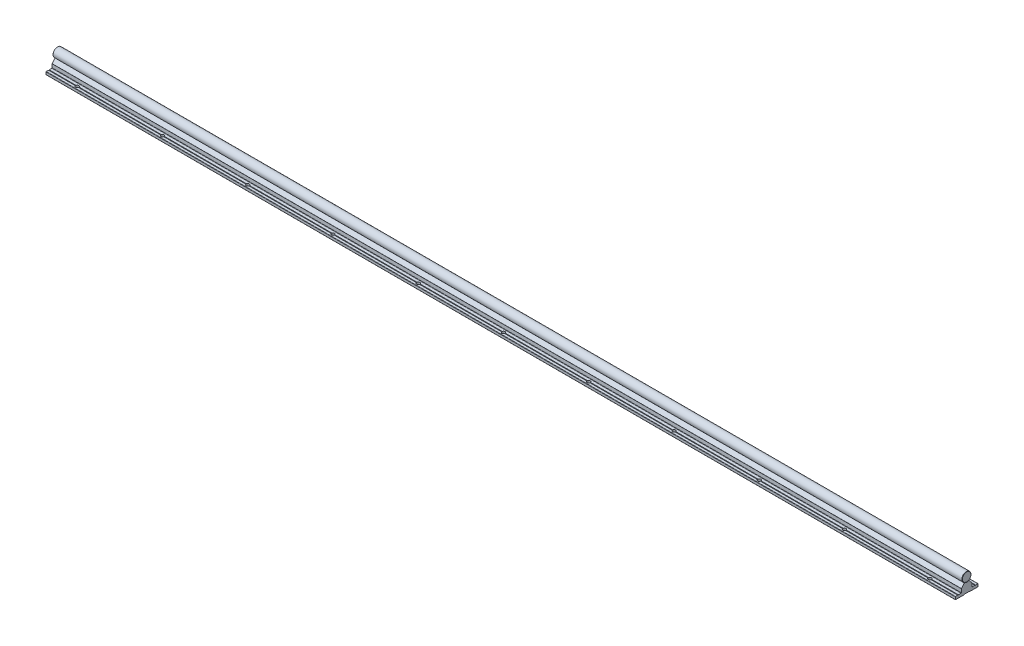
from build123d import *

# Parameters (mm, degrees)
EXTRUDE_6718_DEPTH       = 1500
SKETCH_1_3_R             = 8
EXTRUDE_6847_DEPTH       = 1500
FILLET_4_R               = 0.2
SKETCH_2_R               = 2.75
CUT_EXTRUDE_1_DEPTH      = 6
PATTERN_LINEAR_1_COUNT   = 20
PATTERN_LINEAR_1_PITCH   = 150
PATTERN_LINEAR_2_COUNT   = 20
PATTERN_LINEAR_2_PITCH   = 150
FILLET_1_R               = 0.3
CUT_EXTRUDE_2_DEPTH      = 3
FILLET_2_R               = 0.3
PATTERN_LINEAR_3_COUNT   = 20
PATTERN_LINEAR_3_PITCH   = 150
CHAMFER_1_SIZE           = 0.5
FILLET_3_R               = 0.5
FILLET_5_R               = 0.2
FILLET_6_R               = 0.1
FILLET_7_R               = 0.1
SKETCH_7_W               = 3500
SKETCH_7_H               = 1500
SKETCH_7_W_2             = 1600
SKETCH_7_H_2             = 1000
CUT_EXTRUDE_3_DEPTH      = 9.0000001
CUT_EXTRUDE_3_DEPTH_BACK = 26.0000001
CHAMFER_2_SIZE           = 0.5


with BuildPart() as part:
    # Sketch 1 → Extrude 6718 (new body, symmetric)
    with BuildSketch(Plane(origin=(0, 0, 0), x_dir=(0, 0, -1), z_dir=(1, 0, 0))):
        Polygon((-20, -25), (-4.75, -25), (-4.75, -24.4), (4.75, -24.4), (4.75, -25), (20, -25), (20, -20), (15.5, -20), (15, -20.5), (14.5, -20), (9.25, -20), (9.25, -13.3), (9.110116754, -13.3), (4, -7.21), (3.8, -7.21), (2.309327639, -7.659439004), (0, -8.355703281), (-2.309327657, -7.659438999), (-3.8, -7.21), (-4, -7.21), (-9.110116754, -13.3), (-9.25, -13.3), (-9.25, -20), (-14.5, -20), (-15, -20.5), (-15.5, -20), (-20, -20), align=None)
    extrude(amount=EXTRUDE_6718_DEPTH, both=True)

    # Fillet 4
    fillet_4_edges = [part.edges().sort_by_distance(p)[0] for p in [
        (0, -20, -15.5),
        (0, -24.4, -4.75),
        (0, -24.4, 4.75),
        (0, -20, 15.5),
        (0, -20, 14.5),
        (0, -8.355703281, 0),
        (0, -20, -14.5),
    ]]
    fillet(fillet_4_edges, radius=FILLET_4_R)

    # Sketch 2 → Cut-Extrude 1 (cut, through all)
    with BuildSketch(Plane(origin=(0, -20, 0), x_dir=(1, 0, 0), z_dir=(0, 1, 0))):
        with Locations((-1425, -15)):
            Circle(SKETCH_2_R)
        with Locations((-1425, 15)):
            Circle(SKETCH_2_R)
        with Locations((-1275, -15)):
            Circle(SKETCH_2_R)
        with Locations((-1275, 15)):
            Circle(SKETCH_2_R)
        with Locations((-1125, -15)):
            Circle(SKETCH_2_R)
        with Locations((-1125, 15)):
            Circle(SKETCH_2_R)
        with Locations((-975, -15)):
            Circle(SKETCH_2_R)
        with Locations((-975, 15)):
            Circle(SKETCH_2_R)
        with Locations((-825, -15)):
            Circle(SKETCH_2_R)
        with Locations((-825, 15)):
            Circle(SKETCH_2_R)
        with Locations((-675, -15)):
            Circle(SKETCH_2_R)
        with Locations((-675, 15)):
            Circle(SKETCH_2_R)
        with Locations((-525, -15)):
            Circle(SKETCH_2_R)
        with Locations((-525, 15)):
            Circle(SKETCH_2_R)
        with Locations((-375, -15)):
            Circle(SKETCH_2_R)
        with Locations((-375, 15)):
            Circle(SKETCH_2_R)
        with Locations((-225, -15)):
            Circle(SKETCH_2_R)
        with Locations((-225, 15)):
            Circle(SKETCH_2_R)
        with Locations((-75, -15)):
            Circle(SKETCH_2_R)
        with Locations((-75, 15)):
            Circle(SKETCH_2_R)
        with Locations((75, -15)):
            Circle(SKETCH_2_R)
        with Locations((75, 15)):
            Circle(SKETCH_2_R)
        with Locations((225, -15)):
            Circle(SKETCH_2_R)
        with Locations((225, 15)):
            Circle(SKETCH_2_R)
        with Locations((375, -15)):
            Circle(SKETCH_2_R)
        with Locations((375, 15)):
            Circle(SKETCH_2_R)
        with Locations((525, -15)):
            Circle(SKETCH_2_R)
        with Locations((525, 15)):
            Circle(SKETCH_2_R)
        with Locations((675, -15)):
            Circle(SKETCH_2_R)
        with Locations((675, 15)):
            Circle(SKETCH_2_R)
        with Locations((825, -15)):
            Circle(SKETCH_2_R)
        with Locations((825, 15)):
            Circle(SKETCH_2_R)
        with Locations((975, -15)):
            Circle(SKETCH_2_R)
        with Locations((975, 15)):
            Circle(SKETCH_2_R)
        with Locations((1125, -15)):
            Circle(SKETCH_2_R)
        with Locations((1125, 15)):
            Circle(SKETCH_2_R)
        with Locations((1275, -15)):
            Circle(SKETCH_2_R)
        with Locations((1275, 15)):
            Circle(SKETCH_2_R)
        with Locations((1425, -15)):
            Circle(SKETCH_2_R)
        with Locations((1425, 15)):
            Circle(SKETCH_2_R)
    extrude(amount=-CUT_EXTRUDE_1_DEPTH, mode=Mode.SUBTRACT)

    # Sketch 3 → Cut-Revolve 1 (revolve, cut)
    with BuildSketch(Plane.XY):
        Polygon((-1425, 0), (-1427.2, -1.270170592), (-1427.2, -7.5), (-1427.75, -7.5), (-1427.75, -19), (-1429.75, -19), (-1429.75, -24.4), (-1425, -24.4), align=None)
    cut_revolve_1 = revolve(axis=Axis((-1425, 56.434869358, 0), (0, -1, 0)), mode=Mode.SUBTRACT)

    # Pattern Linear 1: Cut-Revolve 1 ×20
    with Locations(*[(i * PATTERN_LINEAR_1_PITCH, 0, 0) for i in range(1, PATTERN_LINEAR_1_COUNT)]):
        add(cut_revolve_1, mode=Mode.SUBTRACT)

    # Fillet 3
    fillet_3_edges = [part.edges().sort_by_distance(p)[0] for p in [
        (0, -20, -9.25),
        (0, -20, -20),
        (0, -25, -20),
        (0, -25, -4.75),
        (0, -25, 4.75),
        (0, -20, 9.25),
        (0, -25, 20),
        (0, -20, 20),
    ]]
    fillet(fillet_3_edges, radius=FILLET_3_R)

    # Fillet 5
    fillet_5_edges = [part.edges().sort_by_distance(p)[0] for p in [
        (0, -7.21, 4),
        (0, -7.21, 3.8),
        (0, -7.21, -3.8),
        (0, -7.21, -4),
    ]]
    fillet(fillet_5_edges, radius=FILLET_5_R)

    # Fillet 6
    fillet_6_edges = [part.edges().sort_by_distance(p)[0] for p in [
        (0, -13.3, 9.25),
        (0, -13.3, -9.25),
    ]]
    fillet(fillet_6_edges, radius=FILLET_6_R)

    # Fillet 7
    fillet_7_edges = [part.edges().sort_by_distance(p)[0] for p in [
        (0, -13.3, 9.110116754),
        (0, -13.3, -9.110116754),
    ]]
    fillet(fillet_7_edges, radius=FILLET_7_R)


with BuildPart() as body_2:
    # Sketch 1_3 → Extrude 6847 (new body, symmetric)
    with BuildSketch(Plane(origin=(0, 0, 0), x_dir=(0, 0, -1), z_dir=(1, 0, 0))):
        Circle(SKETCH_1_3_R)
    extrude(amount=EXTRUDE_6847_DEPTH, both=True)

    # Sketch 4 → Cut-Revolve 2 (revolve, cut)
    with BuildSketch(Plane.XY):
        Polygon((-1425, -10), (-1427.2, -10), (-1427.2, -1.270170592), (-1425, 0), align=None)
    cut_revolve_2 = revolve(axis=Axis((-1425, 39.840222878, 0), (0, -1, 0)), mode=Mode.SUBTRACT)

    # Pattern Linear 2: Cut-Revolve 2 ×20
    with Locations(*[(i * PATTERN_LINEAR_2_PITCH, 0, 0) for i in range(1, PATTERN_LINEAR_2_COUNT)]):
        add(cut_revolve_2, mode=Mode.SUBTRACT)

    # Chamfer 1
    chamfer_1_edges = [body_2.edges().sort_by_distance(p)[0] for p in [
        (-1500, 0, 8),
        (1500, 0, 8),
    ]]
    chamfer(chamfer_1_edges, length=CHAMFER_1_SIZE)


with BuildPart() as body_3:
    # Sketch 5 → Revolve 1 (revolve)
    with BuildSketch(Plane.XY):
        Polygon((-1425, -24), (-1429.5, -24), (-1429.5, -19), (-1427.5, -19), (-1427.5, -2.461880215), (-1426.7, -2), (-1425, -2), align=None)
    revolve(axis=Axis((-1425, 35.529626596, 0), (0, -1, 0)))

    # Fillet 1
    fillet_1_edges = [body_3.edges().sort_by_distance(p)[0] for p in [
        (-1420.5, -19, 0),
    ]]
    fillet(fillet_1_edges, radius=FILLET_1_R)

    # Sketch 6 → Cut-Extrude 2 (cut)
    with BuildSketch(Plane.XZ.offset(24)):
        Polygon((-1423.25, -1.010362971), (-1423.25, 1.010362971), (-1425, 2.020725942), (-1426.75, 1.010362971), (-1426.75, -1.010362971), (-1425, -2.020725942), align=None)
    extrude(amount=-CUT_EXTRUDE_2_DEPTH, mode=Mode.SUBTRACT)

    # Fillet 2
    fillet_2_edges = [body_3.edges().sort_by_distance(p)[0] for p in [
        (-1424.125, -24, -1.515544457),
        (-1423.25, -24, 0),
        (-1424.125, -24, 1.515544457),
        (-1425.875, -24, 1.515544457),
        (-1426.75, -24, 0),
        (-1425.875, -24, -1.515544457),
        (-1420.5, -24, 0),
    ]]
    fillet(fillet_2_edges, radius=FILLET_2_R)


with BuildPart() as pattern_linear_3_1:
    # Pattern Linear 3: pattern copy
    add(body_3.part.moved(Location(Vector(1, 0, 0) * (1 * PATTERN_LINEAR_3_PITCH))))


with BuildPart() as pattern_linear_3_2:
    # Pattern Linear 3: pattern copy
    add(body_3.part.moved(Location(Vector(1, 0, 0) * (2 * PATTERN_LINEAR_3_PITCH))))


with BuildPart() as pattern_linear_3_3:
    # Pattern Linear 3: pattern copy
    add(body_3.part.moved(Location(Vector(1, 0, 0) * (3 * PATTERN_LINEAR_3_PITCH))))


with BuildPart() as pattern_linear_3_4:
    # Pattern Linear 3: pattern copy
    add(body_3.part.moved(Location(Vector(1, 0, 0) * (4 * PATTERN_LINEAR_3_PITCH))))


with BuildPart() as pattern_linear_3_5:
    # Pattern Linear 3: pattern copy
    add(body_3.part.moved(Location(Vector(1, 0, 0) * (5 * PATTERN_LINEAR_3_PITCH))))


with BuildPart() as pattern_linear_3_6:
    # Pattern Linear 3: pattern copy
    add(body_3.part.moved(Location(Vector(1, 0, 0) * (6 * PATTERN_LINEAR_3_PITCH))))


with BuildPart() as pattern_linear_3_7:
    # Pattern Linear 3: pattern copy
    add(body_3.part.moved(Location(Vector(1, 0, 0) * (7 * PATTERN_LINEAR_3_PITCH))))


with BuildPart() as pattern_linear_3_8:
    # Pattern Linear 3: pattern copy
    add(body_3.part.moved(Location(Vector(1, 0, 0) * (8 * PATTERN_LINEAR_3_PITCH))))


with BuildPart() as pattern_linear_3_9:
    # Pattern Linear 3: pattern copy
    add(body_3.part.moved(Location(Vector(1, 0, 0) * (9 * PATTERN_LINEAR_3_PITCH))))


with BuildPart() as pattern_linear_3_10:
    # Pattern Linear 3: pattern copy
    add(body_3.part.moved(Location(Vector(1, 0, 0) * (10 * PATTERN_LINEAR_3_PITCH))))


with BuildPart() as pattern_linear_3_11:
    # Pattern Linear 3: pattern copy
    add(body_3.part.moved(Location(Vector(1, 0, 0) * (11 * PATTERN_LINEAR_3_PITCH))))


with BuildPart() as pattern_linear_3_12:
    # Pattern Linear 3: pattern copy
    add(body_3.part.moved(Location(Vector(1, 0, 0) * (12 * PATTERN_LINEAR_3_PITCH))))


with BuildPart() as pattern_linear_3_13:
    # Pattern Linear 3: pattern copy
    add(body_3.part.moved(Location(Vector(1, 0, 0) * (13 * PATTERN_LINEAR_3_PITCH))))


with BuildPart() as pattern_linear_3_14:
    # Pattern Linear 3: pattern copy
    add(body_3.part.moved(Location(Vector(1, 0, 0) * (14 * PATTERN_LINEAR_3_PITCH))))


with BuildPart() as pattern_linear_3_15:
    # Pattern Linear 3: pattern copy
    add(body_3.part.moved(Location(Vector(1, 0, 0) * (15 * PATTERN_LINEAR_3_PITCH))))


with BuildPart() as pattern_linear_3_16:
    # Pattern Linear 3: pattern copy
    add(body_3.part.moved(Location(Vector(1, 0, 0) * (16 * PATTERN_LINEAR_3_PITCH))))


with BuildPart() as pattern_linear_3_17:
    # Pattern Linear 3: pattern copy
    add(body_3.part.moved(Location(Vector(1, 0, 0) * (17 * PATTERN_LINEAR_3_PITCH))))


with BuildPart() as pattern_linear_3_18:
    # Pattern Linear 3: pattern copy
    add(body_3.part.moved(Location(Vector(1, 0, 0) * (18 * PATTERN_LINEAR_3_PITCH))))


with BuildPart() as pattern_linear_3_19:
    # Pattern Linear 3: pattern copy
    add(body_3.part.moved(Location(Vector(1, 0, 0) * (19 * PATTERN_LINEAR_3_PITCH))))


with BuildPart() as cut_extrude_3_tool:
    # Sketch 7 → Cut-Extrude 3 (new body, two sides)
    with BuildSketch(Plane(origin=(0, 0, 0), x_dir=(1, 0, 0), z_dir=(0, 1, 0))) as cut_extrude_3_sk:
        Rectangle(SKETCH_7_W, SKETCH_7_H)
        with Locations((-75, 0)):
            Rectangle(SKETCH_7_W_2, SKETCH_7_H_2, mode=Mode.SUBTRACT)
    extrude(amount=CUT_EXTRUDE_3_DEPTH)
    extrude(cut_extrude_3_sk.sketch, amount=-CUT_EXTRUDE_3_DEPTH_BACK)


with BuildPart() as part_1:
    add(part.part)

    # Cut-Extrude 3: cut by cut_extrude_3_tool
    add(cut_extrude_3_tool.part, mode=Mode.SUBTRACT)


with BuildPart() as body_2_1:
    add(body_2.part)

    # Cut-Extrude 3: cut by cut_extrude_3_tool
    add(cut_extrude_3_tool.part, mode=Mode.SUBTRACT)

    # Chamfer 2
    chamfer_2_edges = [body_2_1.edges().sort_by_distance(p)[0] for p in [
        (-875, 0, 8),
        (725, 0, 8),
    ]]
    chamfer(chamfer_2_edges, length=CHAMFER_2_SIZE)


with BuildPart() as body_3_1:
    add(body_3.part)

    # Cut-Extrude 3: cut by cut_extrude_3_tool
    add(cut_extrude_3_tool.part, mode=Mode.SUBTRACT)


with BuildPart() as pattern_linear_3_1_1:
    add(pattern_linear_3_1.part)

    # Cut-Extrude 3: cut by cut_extrude_3_tool
    add(cut_extrude_3_tool.part, mode=Mode.SUBTRACT)


with BuildPart() as pattern_linear_3_2_1:
    add(pattern_linear_3_2.part)

    # Cut-Extrude 3: cut by cut_extrude_3_tool
    add(cut_extrude_3_tool.part, mode=Mode.SUBTRACT)


with BuildPart() as pattern_linear_3_3_1:
    add(pattern_linear_3_3.part)

    # Cut-Extrude 3: cut by cut_extrude_3_tool
    add(cut_extrude_3_tool.part, mode=Mode.SUBTRACT)


with BuildPart() as pattern_linear_3_15_1:
    add(pattern_linear_3_15.part)

    # Cut-Extrude 3: cut by cut_extrude_3_tool
    add(cut_extrude_3_tool.part, mode=Mode.SUBTRACT)


with BuildPart() as pattern_linear_3_16_1:
    add(pattern_linear_3_16.part)

    # Cut-Extrude 3: cut by cut_extrude_3_tool
    add(cut_extrude_3_tool.part, mode=Mode.SUBTRACT)


with BuildPart() as pattern_linear_3_17_1:
    add(pattern_linear_3_17.part)

    # Cut-Extrude 3: cut by cut_extrude_3_tool
    add(cut_extrude_3_tool.part, mode=Mode.SUBTRACT)


with BuildPart() as pattern_linear_3_18_1:
    add(pattern_linear_3_18.part)

    # Cut-Extrude 3: cut by cut_extrude_3_tool
    add(cut_extrude_3_tool.part, mode=Mode.SUBTRACT)


with BuildPart() as pattern_linear_3_19_1:
    add(pattern_linear_3_19.part)

    # Cut-Extrude 3: cut by cut_extrude_3_tool
    add(cut_extrude_3_tool.part, mode=Mode.SUBTRACT)


solid = Compound([pattern_linear_3_4.part, pattern_linear_3_5.part, pattern_linear_3_6.part, pattern_linear_3_7.part, pattern_linear_3_8.part, pattern_linear_3_9.part, pattern_linear_3_10.part, pattern_linear_3_11.part, pattern_linear_3_12.part, pattern_linear_3_13.part, pattern_linear_3_14.part, part_1.part, body_2_1.part])
